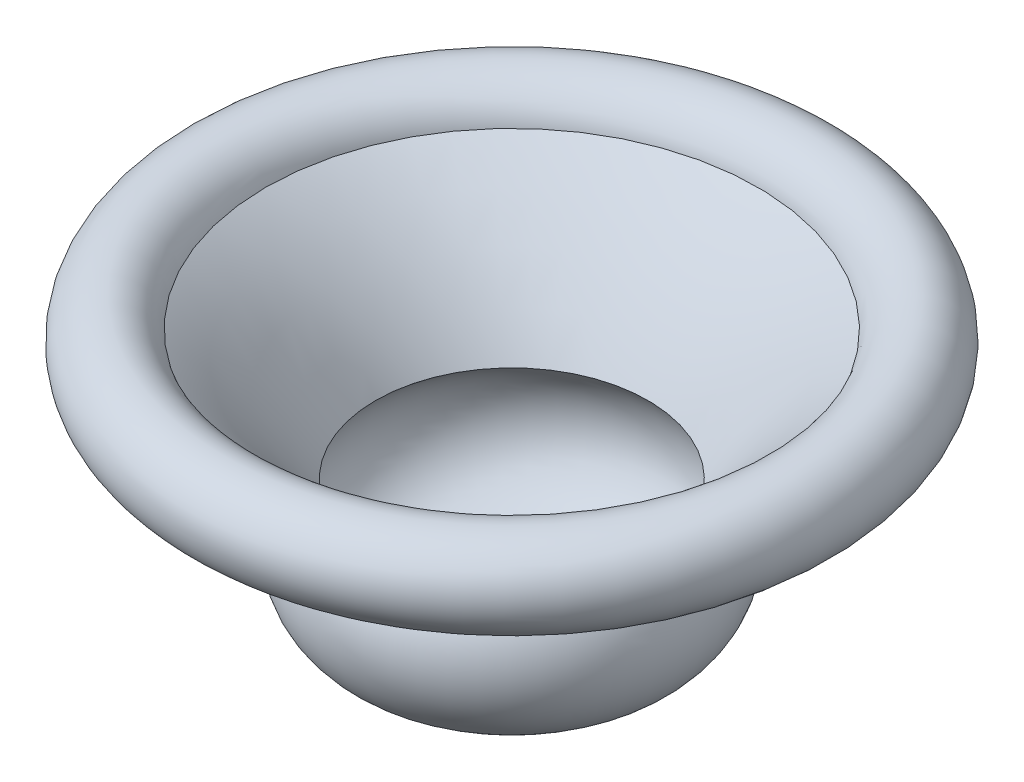
from build123d import *


with BuildPart() as part:
    # Sketch1 → Revolve3 (revolve)
    with BuildSketch(Plane.XY):
        with BuildLine():
            Line((108.142472648, 68.303793264), (105.435679653, 72.507752313))
            ThreePointArc((105.435679653, 72.507752313), (105.186858116, 89.209212345), (90.305192349, 81.623917139))
            ThreePointArc((90.305192349, 81.623917139), (69.943889026, 62.808520252), (53.786632085, 40.279763491))
            ThreePointArc((53.786632085, 40.279763491), (58.250408582, 6.29326402), (26.769075096, -7.268929344))
            Line((26.769075096, -7.268929344), (19.14648892, -7.268929344))
            ThreePointArc((19.14648892, -7.268929344), (14.070662777, -5.884960273), (10.399793912, -2.116127136))
            ThreePointArc((10.399793912, -2.116127136), (6.033604202, 2.341818935), (0, 3.933207033))
            Line((0, 3.933207033), (0, 8.933422141))
            ThreePointArc((0, 8.933422141), (8.571545008, 6.649880477), (14.773141416, 0.30747176))
            ThreePointArc((14.773141416, 0.30747176), (16.608575848, -1.576944808), (19.14648892, -2.268929344))
            Line((19.14648892, -2.268929344), (27.960178268, -2.412874028))
            ThreePointArc((27.960178268, -2.412874028), (54.746153911, 10.392341354), (47.455873554, 39.172783402))
            ThreePointArc((47.455873554, 39.172783402), (64.202712024, 63.811987638), (85.721012261, 84.415621761))
            ThreePointArc((85.721012261, 84.415621761), (108.768587007, 92.832036603), (108.142472648, 68.303793264))
        make_face()
    revolve(axis=Axis((0, 0, 0), (0, -1, 0)))


solid = part.part
